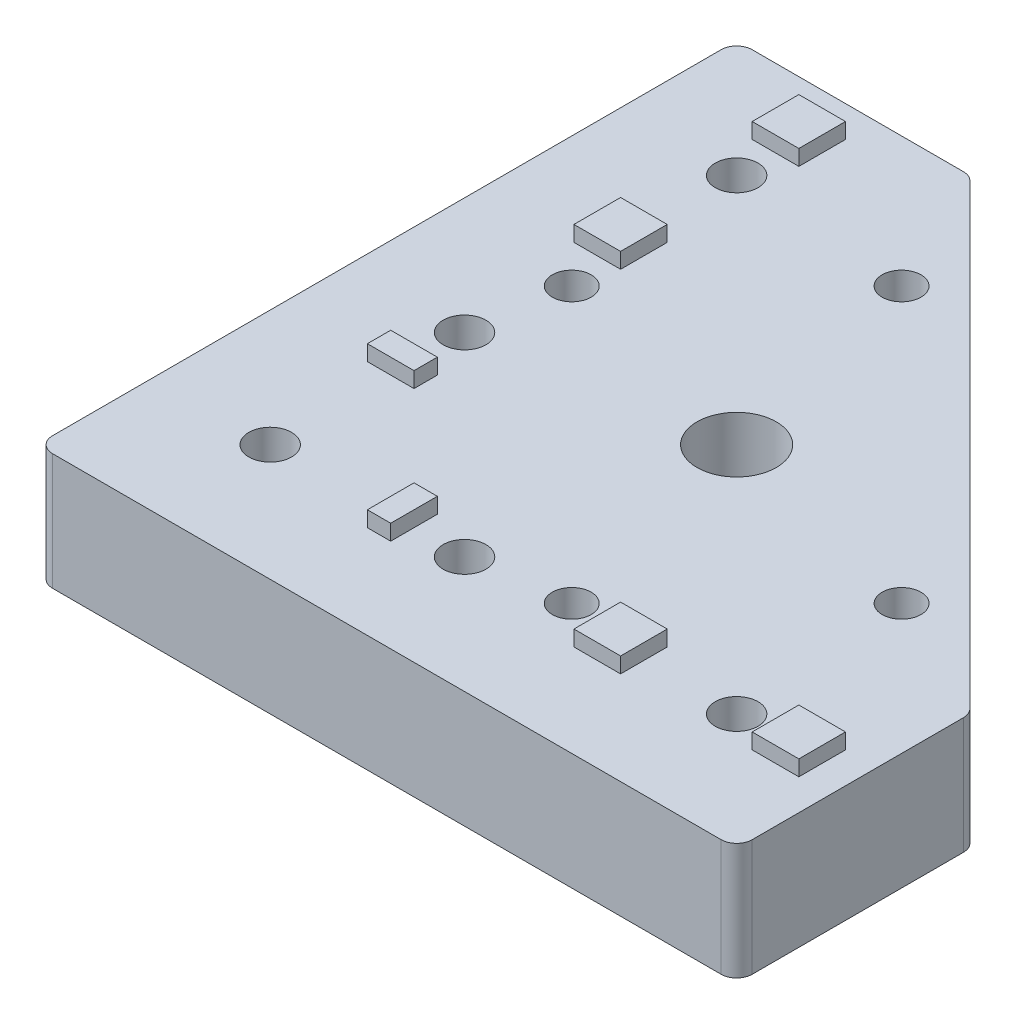
from build123d import *

# Parameters (mm, degrees)
EXTRUDE_1_DEPTH             = 15
HOLE_WIZARD_M121_D          = 10.2
HOLE_WIZARD_M121_DEPTH      = 15
HOLE_WIZARD_M61_D           = 5
HOLE_WIZARD_M61_DEPTH       = 15
HOLE_WIZARD_5_5_5_5_1_D     = 5.5
HOLE_WIZARD_5_5_5_5_1_DEPTH = 15
SKETCH_9_W                  = 6
SKETCH_9_H                  = 6
SKETCH_9_H_2                = 3
SKETCH_9_W_2                = 3
EXTRUDE_2_DEPTH             = 2
FILLET_1_R                  = 2


with BuildPart() as part:
    # Эскиз1 → Бобышка-Вытянуть1 (new body)
    with BuildSketch(Plane(origin=(0, 0, 0), x_dir=(1, 0, 0), z_dir=(0, 1, 0))):
        Polygon((0, 0), (0, 90), (30, 90), (90, 30), (90, 0), align=None)
    extrude(amount=EXTRUDE_1_DEPTH)

    # Отверстие обработанное метчиком M121
    with Locations(Plane(origin=(0, 15, 0), x_dir=(1, 0, 0), z_dir=(0, 1, 0))):
        with Locations((45, 45)):
            Hole(HOLE_WIZARD_M121_D / 2, depth=HOLE_WIZARD_M121_DEPTH)

    # Отверстие обработанное метчиком M61
    with Locations(Plane(origin=(0, 15, 0), x_dir=(1, 0, 0), z_dir=(0, 1, 0))):
        with Locations((37.928932188, 73.284271247), (73.284271247, 37.928932188), (52.071067812, 16.715728753), (16.715728753, 52.071067812)):
            Hole(HOLE_WIZARD_M61_D / 2, depth=HOLE_WIZARD_M61_DEPTH)

    # Диаметр отверстия Ø5.5 (5.5)1
    with Locations(Plane(origin=(0, 15, 0), x_dir=(1, 0, 0), z_dir=(0, 1, 0))):
        with Locations((15, 75), (15, 40), (15, 15), (40, 15), (75, 15)):
            Hole(HOLE_WIZARD_5_5_5_5_1_D / 2, depth=HOLE_WIZARD_5_5_5_5_1_DEPTH)

    # Эскиз9 → Бобышка-Вытянуть2 (add)
    with BuildSketch(Plane(origin=(0, 15, 0), x_dir=(1, 0, 0), z_dir=(0, 1, 0))):
        with Locations((15, 83)):
            Rectangle(SKETCH_9_W, SKETCH_9_H)
        with Locations((15, 60.071067812)):
            Rectangle(SKETCH_9_W, SKETCH_9_H)
        with Locations((15, 32)):
            Rectangle(SKETCH_9_W, SKETCH_9_H_2)
        with Locations((32, 15)):
            Rectangle(SKETCH_9_W_2, SKETCH_9_H)
        with Locations((60.071067812, 15)):
            Rectangle(SKETCH_9_W, SKETCH_9_H)
        with Locations((83, 15)):
            Rectangle(SKETCH_9_W, SKETCH_9_H)
    extrude(amount=EXTRUDE_2_DEPTH)

    # Скругление1
    fillet_1_edges = [part.edges().sort_by_distance(p)[0] for p in [
        (0, 7.5, 0),
        (0, 7.5, -90),
        (30, 7.5, -90),
        (90, 7.5, -30),
        (90, 7.5, 0),
    ]]
    fillet(fillet_1_edges, radius=FILLET_1_R)


solid = part.part
